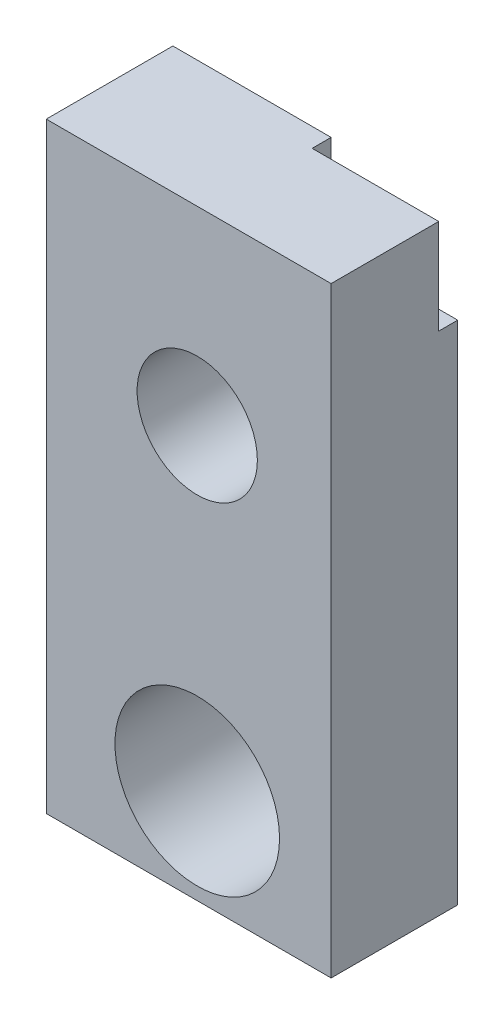
from build123d import *

# Parameters (mm, degrees)
SKIZZE1_W                       = 43
SKIZZE1_H                       = 95
AUFSATZ_LINEAR_AUSTRAGEN1_DEPTH = 20
SKIZZE2_R                       = 13
SCHNITT_LINEAR_AUSTRAGEN1_DEPTH = 34
SKIZZE3_R                       = 9.5
SCHNITT_LINEAR_AUSTRAGEN2_DEPTH = 34
SKIZZE4_W                       = 20
SKIZZE4_H                       = 3
SCHNITT_LINEAR_AUSTRAGEN3_DEPTH = 15
SKIZZE8_R                       = 1.62
SCHNITT_LINEAR_AUSTRAGEN6_DEPTH = 5
SKIZZE9_R                       = 1.62
SCHNITT_LINEAR_AUSTRAGEN7_DEPTH = 5
SKIZZE10_R                      = 1.5
SCHNITT_LINEAR_AUSTRAGEN8_DEPTH = 12
SKIZZE11_W                      = 20
SKIZZE11_H                      = 95
AUFSATZ_LINEAR_AUSTRAGEN2_DEPTH = 2


with BuildPart() as part:
    # Skizze1 → Aufsatz-Linear austragen1 (new body)
    with BuildSketch(Plane.XY):
        with Locations((21.5, 47.5)):
            Rectangle(SKIZZE1_W, SKIZZE1_H)
    extrude(amount=AUFSATZ_LINEAR_AUSTRAGEN1_DEPTH)

    # Skizze2 → Schnitt-Linear austragen1 (cut)
    with BuildSketch(Plane.XY.offset(20)):
        with Locations((21.85, 15)):
            Circle(SKIZZE2_R)
    extrude(amount=-SCHNITT_LINEAR_AUSTRAGEN1_DEPTH, mode=Mode.SUBTRACT)

    # Skizze3 → Schnitt-Linear austragen2 (cut)
    with BuildSketch(Plane.XY.offset(20)):
        with Locations((21.85, 65)):
            Circle(SKIZZE3_R)
    extrude(amount=-SCHNITT_LINEAR_AUSTRAGEN2_DEPTH, mode=Mode.SUBTRACT)

    # Skizze4 → Schnitt-Linear austragen3 (cut)
    with BuildSketch(Plane(origin=(0, 95, 0), x_dir=(1, 0, 0), z_dir=(0, 1, 0))):
        with Locations((33, -1.5)):
            Rectangle(SKIZZE4_W, SKIZZE4_H)
    extrude(amount=-SCHNITT_LINEAR_AUSTRAGEN3_DEPTH, mode=Mode.SUBTRACT)

    # Skizze8 → Schnitt-Linear austragen6 (cut)
    with BuildSketch(Plane(origin=(0, 0, 3), x_dir=(-1, 0, 0), z_dir=(0, 0, -1))):
        with Locations((-38, 86)):
            Circle(SKIZZE8_R)
    extrude(amount=-SCHNITT_LINEAR_AUSTRAGEN6_DEPTH, mode=Mode.SUBTRACT)

    # Skizze9 → Schnitt-Linear austragen7 (cut)
    with BuildSketch(Plane(origin=(0, 0, 3), x_dir=(-1, 0, 0), z_dir=(0, 0, -1))):
        with Locations((-28, 86)):
            Circle(SKIZZE9_R)
    extrude(amount=-SCHNITT_LINEAR_AUSTRAGEN7_DEPTH, mode=Mode.SUBTRACT)

    # Skizze10 → Schnitt-Linear austragen8 (cut)
    with BuildSketch(Plane(origin=(0, 0, 0), x_dir=(-1, 0, 0), z_dir=(0, 0, -1))):
        with Locations((-4.35, 15)):
            Circle(SKIZZE10_R)
        with Locations((-39.35, 15)):
            Circle(SKIZZE10_R)
    extrude(amount=-SCHNITT_LINEAR_AUSTRAGEN8_DEPTH, mode=Mode.SUBTRACT)

    # Skizze11 → Aufsatz-Linear austragen2 (add)
    with BuildSketch(Plane.ZY):
        with Locations((10, 47.5)):
            Rectangle(SKIZZE11_W, SKIZZE11_H)
    extrude(amount=AUFSATZ_LINEAR_AUSTRAGEN2_DEPTH)


solid = part.part
